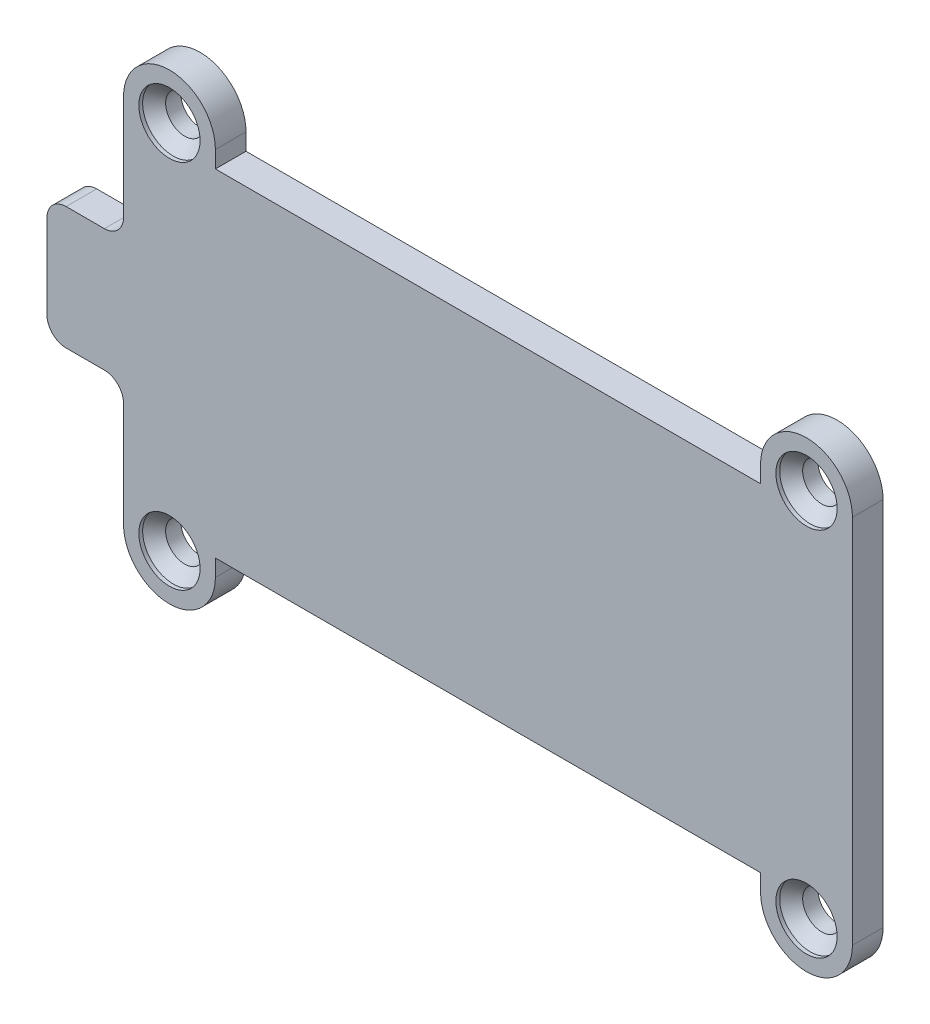
from build123d import *

# Parameters (mm, degrees)
SKETCH1_R                                      = 1.25
BOSS_EXTRUDE1_DEPTH                            = 2
CSK_FOR_M2_FLAT_HEAD_MACHINE_SCREW1_AT_2_COUNT = 2
CSK_FOR_M2_FLAT_HEAD_MACHINE_SCREW1_AT_2_PITCH = 41.6
CSK_FOR_M2_FLAT_HEAD_MACHINE_SCREW1_AT_3_COUNT = 2
CSK_FOR_M2_FLAT_HEAD_MACHINE_SCREW1_AT_3_PITCH = 48.126915546
CSK_FOR_M2_FLAT_HEAD_MACHINE_SCREW1_AT_4_COUNT = 2
CSK_FOR_M2_FLAT_HEAD_MACHINE_SCREW1_AT_4_PITCH = 24.2


with BuildPart() as part:
    # Sketch1 → Boss-Extrude1 (new body)
    with BuildSketch(Plane.XY):
        with BuildLine():
            Line((-28.8, 2.25), (-28.8, -2.25))
            Line((-28.8, -2.25), (-28.8, -2.75))
            ThreePointArc((-28.8, -2.75), (-28.433883476, -3.633883476), (-27.55, -4))
            Line((-27.55, -4), (-25.05, -4))
            ThreePointArc((-25.05, -4), (-24.166116524, -4.366116524), (-23.8, -5.25))
            Line((-23.8, -5.25), (-23.8, -12.1))
            ThreePointArc((-23.8, -12.1), (-20.8, -15.1), (-17.8, -12.1))
            Line((-17.8, -12.1), (-17.8, -11))
            Line((-17.8, -11), (17.8, -11))
            Line((17.8, -11), (17.8, -12.1))
            ThreePointArc((17.8, -12.1), (20.8, -15.1), (23.8, -12.1))
            Line((23.8, -12.1), (23.8, 12.1))
            ThreePointArc((23.8, 12.1), (20.8, 15.1), (17.8, 12.1))
            Line((17.8, 12.1), (17.8, 11))
            Line((17.8, 11), (-17.8, 11))
            Line((-17.8, 11), (-17.8, 12.1))
            ThreePointArc((-17.8, 12.1), (-20.8, 15.1), (-23.8, 12.1))
            Line((-23.8, 12.1), (-23.8, 5.25))
            ThreePointArc((-23.8, 5.25), (-24.166116524, 4.366116524), (-25.05, 4))
            Line((-25.05, 4), (-27.55, 4))
            ThreePointArc((-27.55, 4), (-28.433883476, 3.633883476), (-28.8, 2.75))
            Line((-28.8, 2.75), (-28.8, 2.25))
        make_face()
        with Locations((-20.8, 12.1)):
            Circle(SKETCH1_R, mode=Mode.SUBTRACT)
        with Locations((20.8, 12.1)):
            Circle(SKETCH1_R, mode=Mode.SUBTRACT)
        with Locations((20.8, -12.1)):
            Circle(SKETCH1_R, mode=Mode.SUBTRACT)
        with Locations((-20.8, -12.1)):
            Circle(SKETCH1_R, mode=Mode.SUBTRACT)
    extrude(amount=BOSS_EXTRUDE1_DEPTH)

    # Sketch3 → CSK for M2 Flat Head Machine Screw1 (revolve, cut)
    with BuildSketch(Plane(origin=(-20.8, 12.1, 2), x_dir=(0, -1, 0), z_dir=(1, 0, 0))):
        Polygon((0, 0), (0, 4.400860619), (1, 3.8), (1, 1.25), (2, 0.25), (2, 0), align=None)
    csk_for_m2_flat_head_machine_screw1 = revolve(axis=Axis((-20.8, 12.1, 8.35), (0, 0, -1)), mode=Mode.SUBTRACT)

    # CSK for M2 Flat Head Machine Screw1 at 2: CSK for M2 Flat Head Machine Screw1 ×2
    with Locations(*[(i * CSK_FOR_M2_FLAT_HEAD_MACHINE_SCREW1_AT_2_PITCH, 0, 0) for i in range(1, CSK_FOR_M2_FLAT_HEAD_MACHINE_SCREW1_AT_2_COUNT)]):
        add(csk_for_m2_flat_head_machine_screw1, mode=Mode.SUBTRACT)

    # CSK for M2 Flat Head Machine Screw1 at 3: CSK for M2 Flat Head Machine Screw1 ×2
    with Locations(*[Vector(0.864381179, -0.502837128, 0) * (i * CSK_FOR_M2_FLAT_HEAD_MACHINE_SCREW1_AT_3_PITCH) for i in range(1, CSK_FOR_M2_FLAT_HEAD_MACHINE_SCREW1_AT_3_COUNT)]):
        add(csk_for_m2_flat_head_machine_screw1, mode=Mode.SUBTRACT)

    # CSK for M2 Flat Head Machine Screw1 at 4: CSK for M2 Flat Head Machine Screw1 ×2
    with Locations(*[(0, -i * CSK_FOR_M2_FLAT_HEAD_MACHINE_SCREW1_AT_4_PITCH, 0) for i in range(1, CSK_FOR_M2_FLAT_HEAD_MACHINE_SCREW1_AT_4_COUNT)]):
        add(csk_for_m2_flat_head_machine_screw1, mode=Mode.SUBTRACT)


solid = part.part
